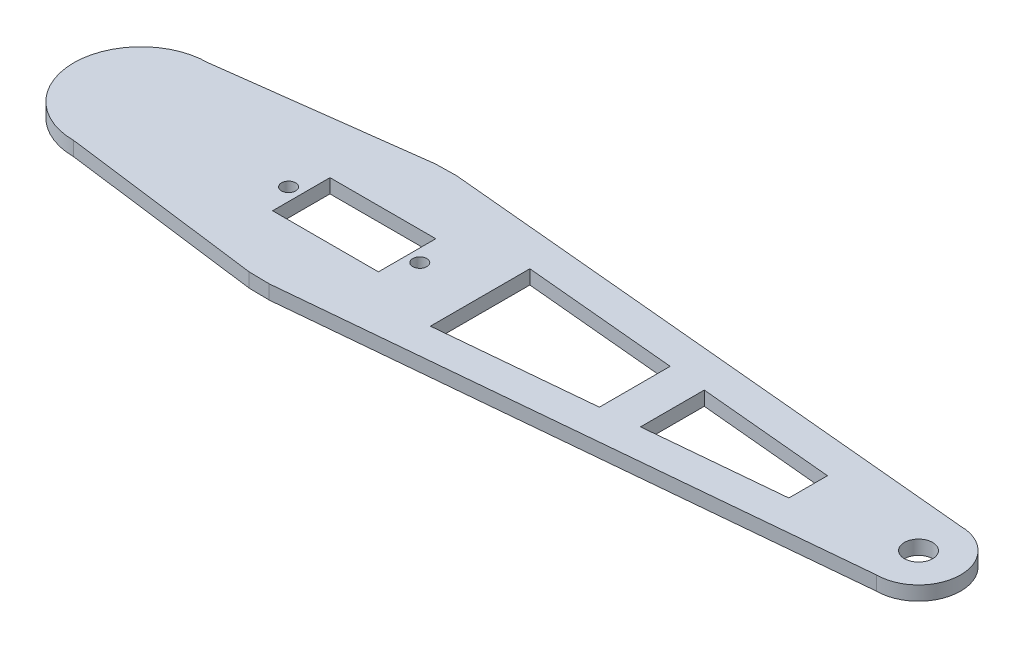
from build123d import *

# Parameters (mm, degrees)
SKETCH1_R           = 1.5
SKETCH1_R_2         = 3
SKETCH1_W           = 22.5
SKETCH1_H           = 12.2
BOSS_EXTRUDE1_DEPTH = 3


with BuildPart() as part:
    # Sketch1 → Boss-Extrude1 (new body)
    with BuildSketch(Plane(origin=(0, 0, 0), x_dir=(1, 0, 0), z_dir=(0, 1, 0))):
        with BuildLine():
            Line((1.846751087, 19.91455524), (120, 8.957763171))
            ThreePointArc((120, 8.957763171), (128.957763171, 0), (120, -8.957763171))
            Line((120, -8.957763171), (1.846751087, -19.91455524))
            Line((1.846751087, -19.91455524), (-2.565887989, -19.834722555))
            Line((-2.565887989, -19.834722555), (-45.343490518, -14.300864634))
            ThreePointArc((-45.343490518, -14.300864634), (-59.644355152, 0), (-45.343490518, 14.300864634))
            Line((-45.343490518, 14.300864634), (-2.565887989, 19.834722555))
            Line((-2.565887989, 19.834722555), (1.846751087, 19.91455524))
        make_face()
        with Locations((13.95, 0)):
            Circle(SKETCH1_R, mode=Mode.SUBTRACT)
        with Locations((-13.95, 0)):
            Circle(SKETCH1_R, mode=Mode.SUBTRACT)
        with Locations((120, 0)):
            Circle(SKETCH1_R_2, mode=Mode.SUBTRACT)
        Rectangle(SKETCH1_W, SKETCH1_H, mode=Mode.SUBTRACT)
        Polygon((96.529167285, 4.104267173), (67.660347399, 6.781380665), (67.660347399, -6.781380665), (96.529167285, -4.104267173), align=None, mode=Mode.SUBTRACT)
        Polygon((59.65913304, 7.523363157), (26.779600723, 10.572404992), (26.779600723, -10.572404992), (59.65913304, -7.523363157), align=None, mode=Mode.SUBTRACT)
    extrude(amount=BOSS_EXTRUDE1_DEPTH)


solid = part.part
